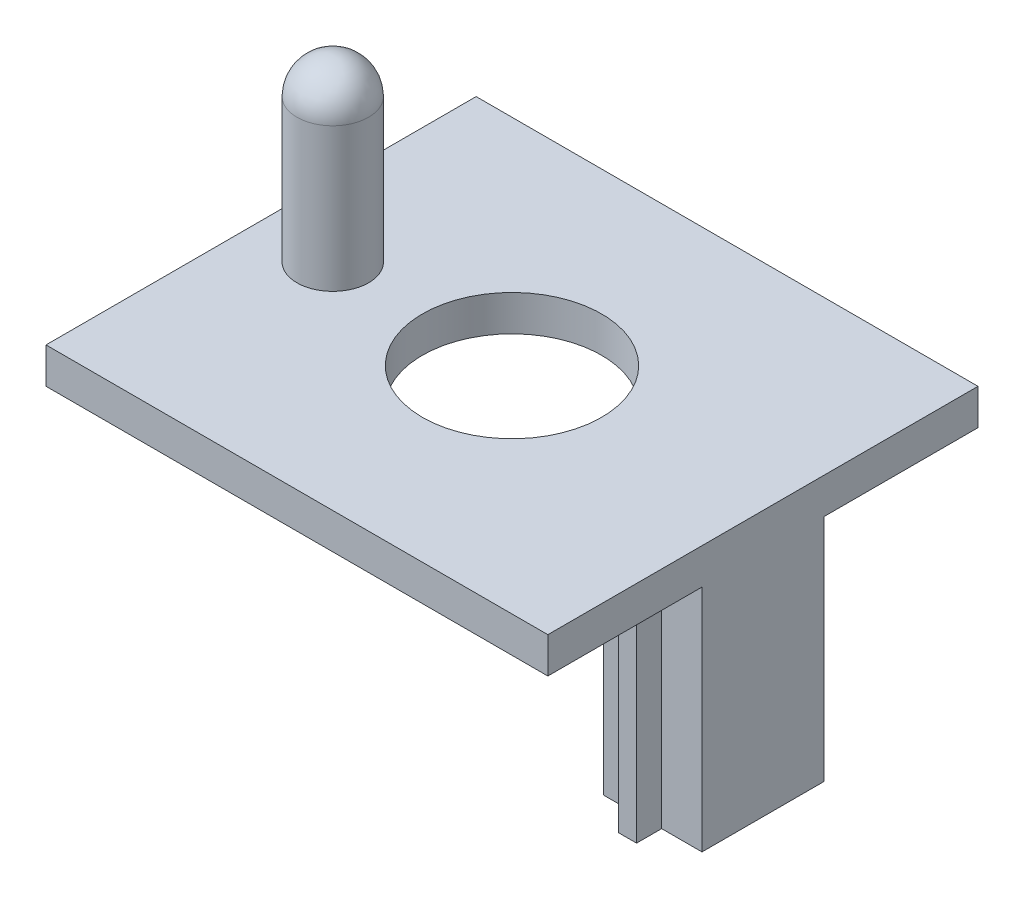
from build123d import *

# Parameters (mm, degrees)
CROQUIS1_W              = 70
CROQUIS1_H              = 60
CROQUIS1_R              = 12.5
SALIENTE_EXTRUIR1_DEPTH = 5
CROQUIS2_W              = 5.625
CROQUIS2_H              = 17
CROQUIS2_W_2            = 2.5
CROQUIS2_H_2            = 3.5
SALIENTE_EXTRUIR2_DEPTH = 32
CROQUIS3_R              = 5
SALIENTE_EXTRUIR3_DEPTH = 25
REDONDEO1_R             = 5


with BuildPart() as part:
    # Croquis1 → Saliente-Extruir1 (new body)
    with BuildSketch(Plane(origin=(0, 0, 0), x_dir=(1, 0, 0), z_dir=(0, 1, 0))):
        Rectangle(CROQUIS1_W, CROQUIS1_H)
        Circle(CROQUIS1_R, mode=Mode.SUBTRACT)
    extrude(amount=SALIENTE_EXTRUIR1_DEPTH)

    # Croquis2 → Saliente-Extruir2 (add)
    with BuildSketch(Plane.XZ):
        with Locations((32.1875, 0)):
            Rectangle(CROQUIS2_W, CROQUIS2_H)
        with Locations((28.125, 0)):
            Rectangle(CROQUIS2_W_2, CROQUIS2_H)
        with Locations((28.125, 10.25)):
            Rectangle(CROQUIS2_W_2, CROQUIS2_H_2)
        with Locations((24.0625, 0)):
            Rectangle(CROQUIS2_W, CROQUIS2_H)
        with Locations((28.125, -10.25)):
            Rectangle(CROQUIS2_W_2, CROQUIS2_H_2)
    extrude(amount=SALIENTE_EXTRUIR2_DEPTH)

    # Croquis3 → Saliente-Extruir3 (add)
    with BuildSketch(Plane(origin=(0, 5, 0), x_dir=(1, 0, 0), z_dir=(0, 1, 0))):
        with Locations((-25, 0)):
            Circle(CROQUIS3_R)
    extrude(amount=SALIENTE_EXTRUIR3_DEPTH)

    # Redondeo1
    redondeo1_edges = [part.edges().sort_by_distance(p)[0] for p in [
        (-30, 30, 0),
    ]]
    fillet(redondeo1_edges, radius=REDONDEO1_R)


solid = part.part
